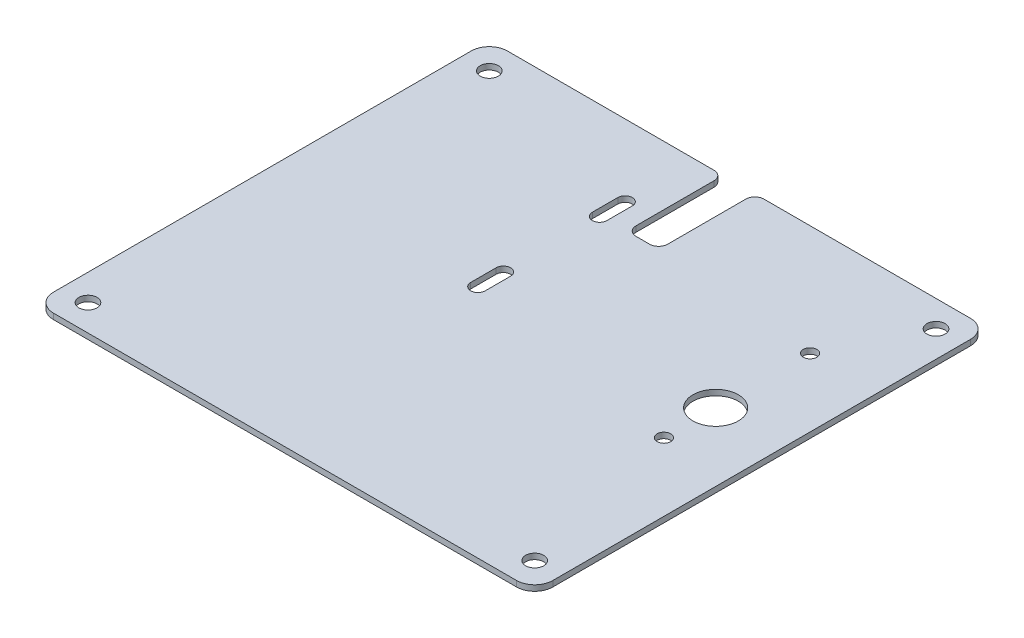
from build123d import *

# Parameters (mm, degrees)
SKETCH1_R           = 2.54
SKETCH1_R_2         = 1.905
SKETCH1_R_3         = 6.35
BOSS_EXTRUDE1_DEPTH = 1.5875
FILLET1_R           = 5.08
FILLET2_R           = 2.54


with BuildPart() as part:
    # Sketch1 → Boss-Extrude1 (new body)
    with BuildSketch(Plane(origin=(0, 0, 0), x_dir=(1, 0, 0), z_dir=(0, 1, 0))):
        Polygon((69.85, 63.5), (4.445, 63.5), (4.445, 36.576), (-4.445, 36.576), (-4.445, 63.5), (-69.85, 63.5), (-69.85, -63.5), (69.85, -63.5), align=None)
        with Locations((-62.484, 56.134)):
            Circle(SKETCH1_R, mode=Mode.SUBTRACT)
        with Locations((-62.484, -56.134)):
            Circle(SKETCH1_R, mode=Mode.SUBTRACT)
        with Locations((62.484, 56.134)):
            Circle(SKETCH1_R, mode=Mode.SUBTRACT)
        with Locations((62.484, -56.134)):
            Circle(SKETCH1_R, mode=Mode.SUBTRACT)
        with Locations((50.8, -8.304005887)):
            Circle(SKETCH1_R_2, mode=Mode.SUBTRACT)
        with Locations((50.8, 32.589994113)):
            Circle(SKETCH1_R_2, mode=Mode.SUBTRACT)
        with Locations((50.8, 6.173994113)):
            Circle(SKETCH1_R_3, mode=Mode.SUBTRACT)
        with BuildLine():
            Line((-9.779, 43.434), (-9.779, 36.322))
            ThreePointArc((-9.779, 36.322), (-11.811, 34.29), (-13.843, 36.322))
            Line((-13.843, 36.322), (-13.843, 43.434))
            ThreePointArc((-13.843, 43.434), (-11.811, 45.466), (-9.779, 43.434))
        make_face(mode=Mode.SUBTRACT)
        with BuildLine():
            Line((-9.779, 9.398), (-9.779, 2.286))
            ThreePointArc((-9.779, 2.286), (-11.811, 0.254), (-13.843, 2.286))
            Line((-13.843, 2.286), (-13.843, 9.398))
            ThreePointArc((-13.843, 9.398), (-11.811, 11.43), (-9.779, 9.398))
        make_face(mode=Mode.SUBTRACT)
    extrude(amount=-BOSS_EXTRUDE1_DEPTH)

    # Fillet1
    fillet1_edges = [part.edges().sort_by_distance(p)[0] for p in [
        (-69.85, -0.79375, -63.5),
        (69.85, -0.79375, -63.5),
        (69.85, -0.79375, 63.5),
        (-69.85, -0.79375, 63.5),
    ]]
    fillet(fillet1_edges, radius=FILLET1_R)

    # Fillet2
    fillet2_edges = [part.edges().sort_by_distance(p)[0] for p in [
        (-4.445, -0.79375, -63.5),
        (-4.445, -0.79375, -36.576),
        (4.445, -0.79375, -36.576),
        (4.445, -0.79375, -63.5),
    ]]
    fillet(fillet2_edges, radius=FILLET2_R)


solid = part.part
